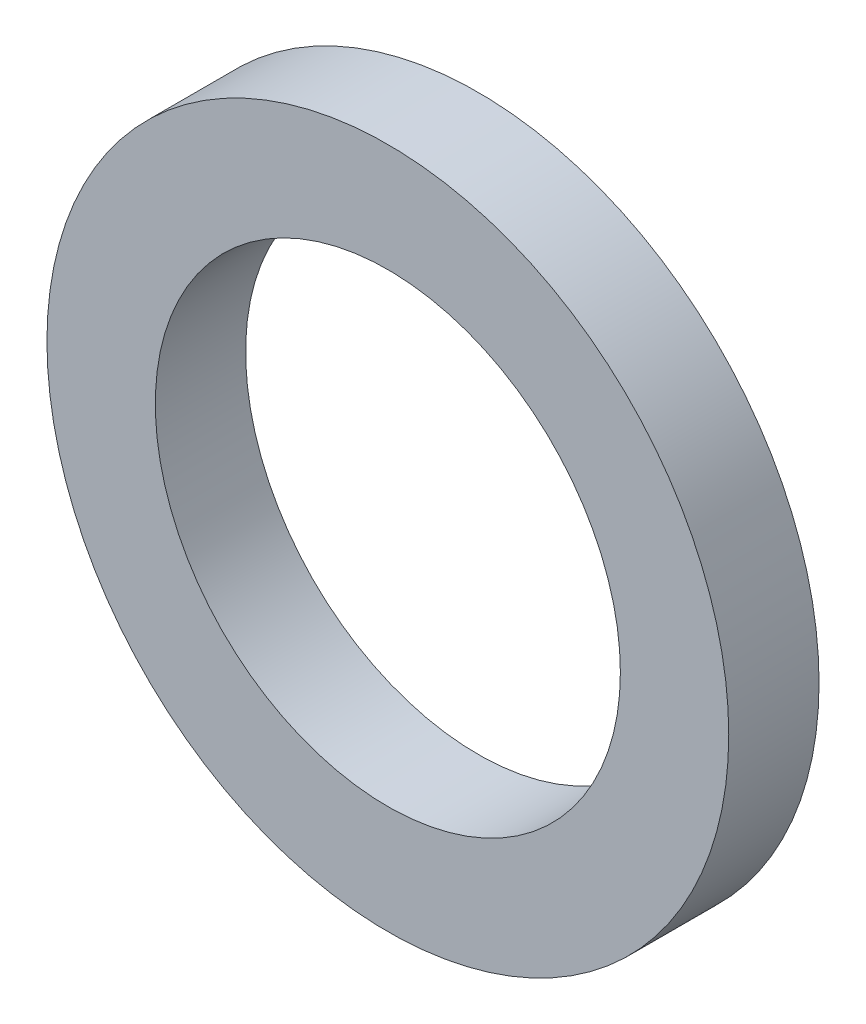
from build123d import *

# Parameters (mm, degrees)
SKETCH1_R           = 3.775
SKETCH1_R_2         = 2.575
BOSS_EXTRUDE1_DEPTH = 1


with BuildPart() as part:
    # Sketch1 → Boss-Extrude1 (new body)
    with BuildSketch(Plane.XY):
        Circle(SKETCH1_R)
        Circle(SKETCH1_R_2, mode=Mode.SUBTRACT)
    extrude(amount=BOSS_EXTRUDE1_DEPTH)


solid = part.part
